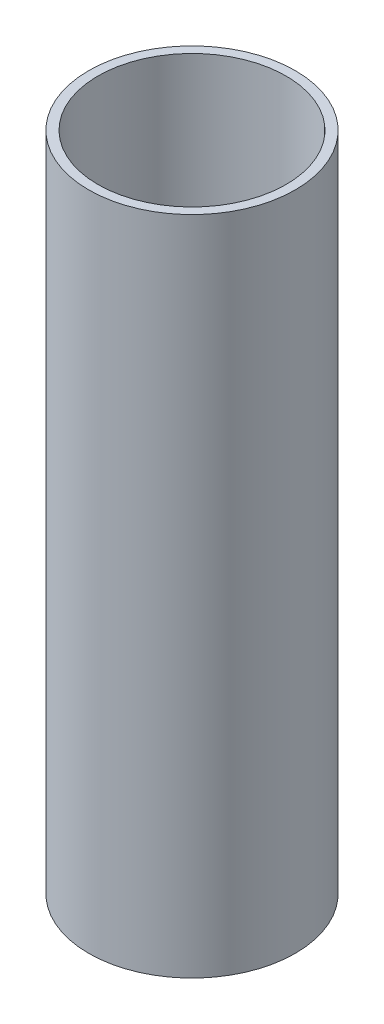
from build123d import *

# Parameters (mm, degrees)
SKETCH1_R           = 7.9375
SKETCH1_R_2         = 7.2263
BOSS_EXTRUDE1_DEPTH = 50.8


with BuildPart() as part:
    # Sketch1 → Boss-Extrude1 (new body)
    with BuildSketch(Plane(origin=(0, 0, 0), x_dir=(1, 0, 0), z_dir=(0, 1, 0))):
        Circle(SKETCH1_R)
        Circle(SKETCH1_R_2, mode=Mode.SUBTRACT)
    extrude(amount=BOSS_EXTRUDE1_DEPTH)


solid = part.part
